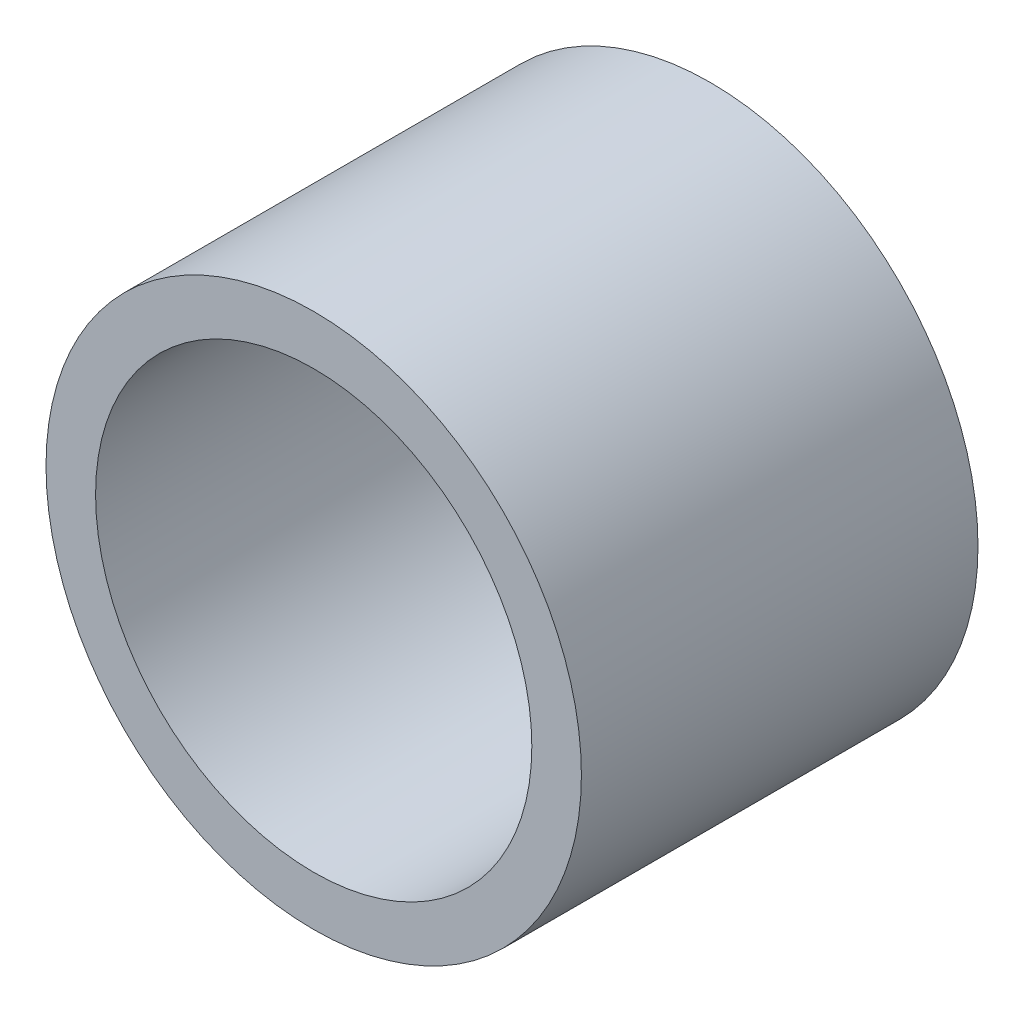
from build123d import *

# Parameters (mm, degrees)
SKETCH1_R           = 6.75
SKETCH1_R_2         = 5.5
BOSS_EXTRUDE1_DEPTH = 10


with BuildPart() as part:
    # Sketch1 → Boss-Extrude1 (new body)
    with BuildSketch(Plane.XY):
        Circle(SKETCH1_R)
        Circle(SKETCH1_R_2, mode=Mode.SUBTRACT)
    extrude(amount=BOSS_EXTRUDE1_DEPTH)


solid = part.part
